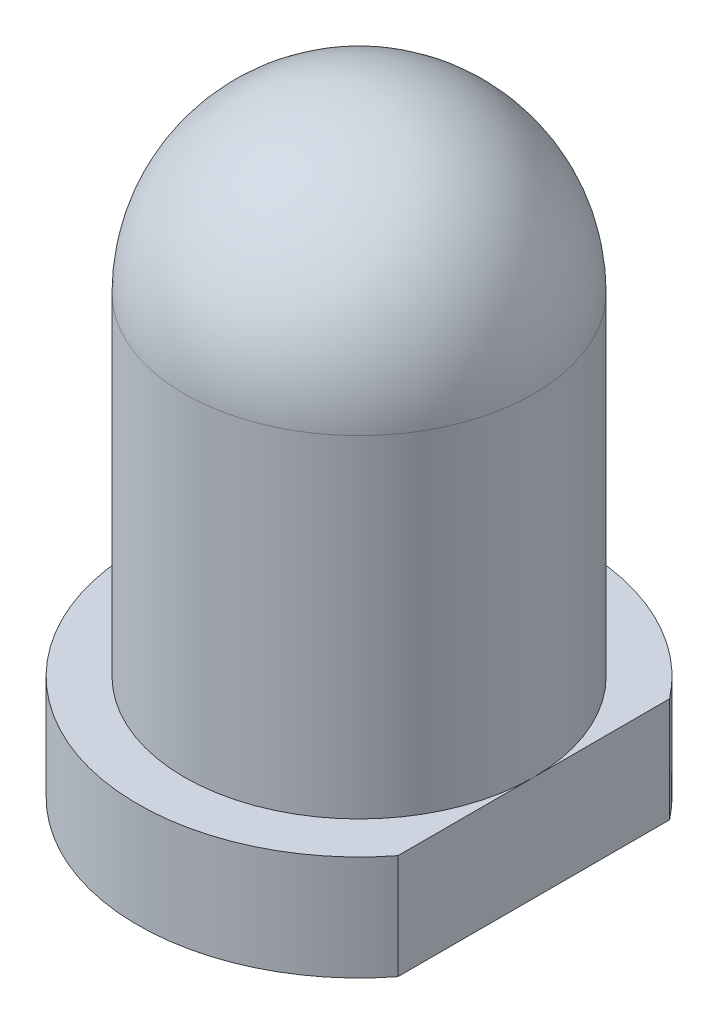
from build123d import *

# Parameters (mm, degrees)
FLANGE_DEPTH = 0.9


with BuildPart() as part:
    # Body Profile → Body (revolve)
    with BuildSketch(Plane.XY):
        with BuildLine():
            Line((1.5, 2.85), (1.5, 0))
            Line((1.5, 0), (0, 0))
            Line((0, 0), (0, 4.35))
            ThreePointArc((0, 4.35), (1.060660172, 3.910660172), (1.5, 2.85))
        make_face()
    revolve(axis=Axis((0, -170.01390881, 0), (0, 1, 0)))

    # Flange Outline → Flange (add)
    with BuildSketch(Plane.XZ):
        with BuildLine():
            Line((1.5, -1.166190379), (1.5, 1.166190379))
            ThreePointArc((1.5, 1.166190379), (-1.9, 0), (1.5, -1.166190379))
        make_face()
    extrude(amount=FLANGE_DEPTH)


solid = part.part
